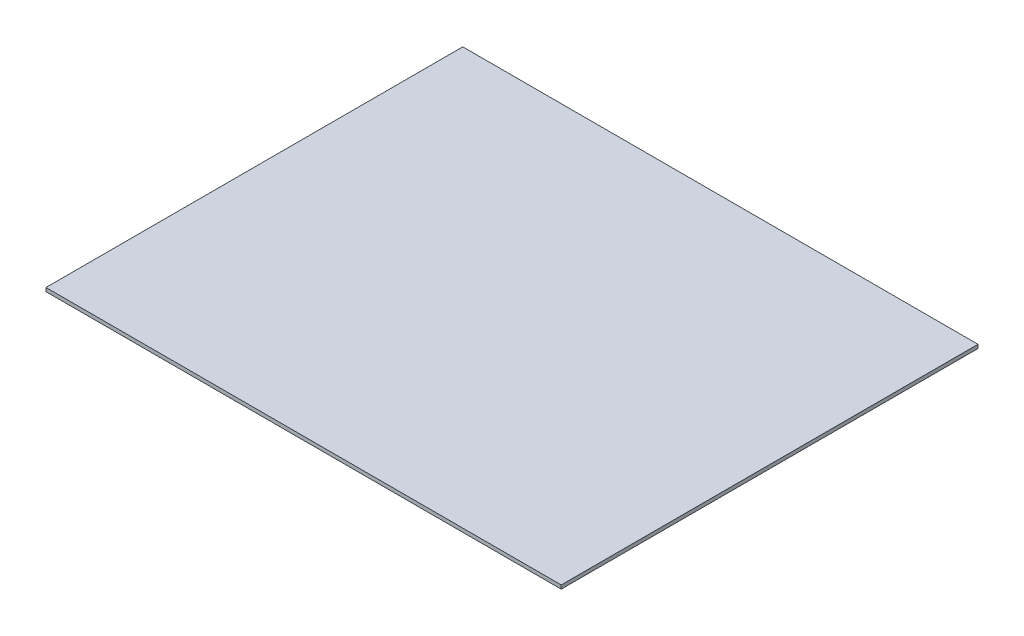
from build123d import *

# Parameters (mm, degrees)
SKETCH1_W           = 246
SKETCH1_H           = 199
BOSS_EXTRUDE1_DEPTH = 1.75


with BuildPart() as part:
    # Sketch1 → Boss-Extrude1 (new body)
    with BuildSketch(Plane(origin=(0, 0, 0), x_dir=(1, 0, 0), z_dir=(0, 1, 0))):
        Rectangle(SKETCH1_W, SKETCH1_H)
    extrude(amount=BOSS_EXTRUDE1_DEPTH)


solid = part.part
